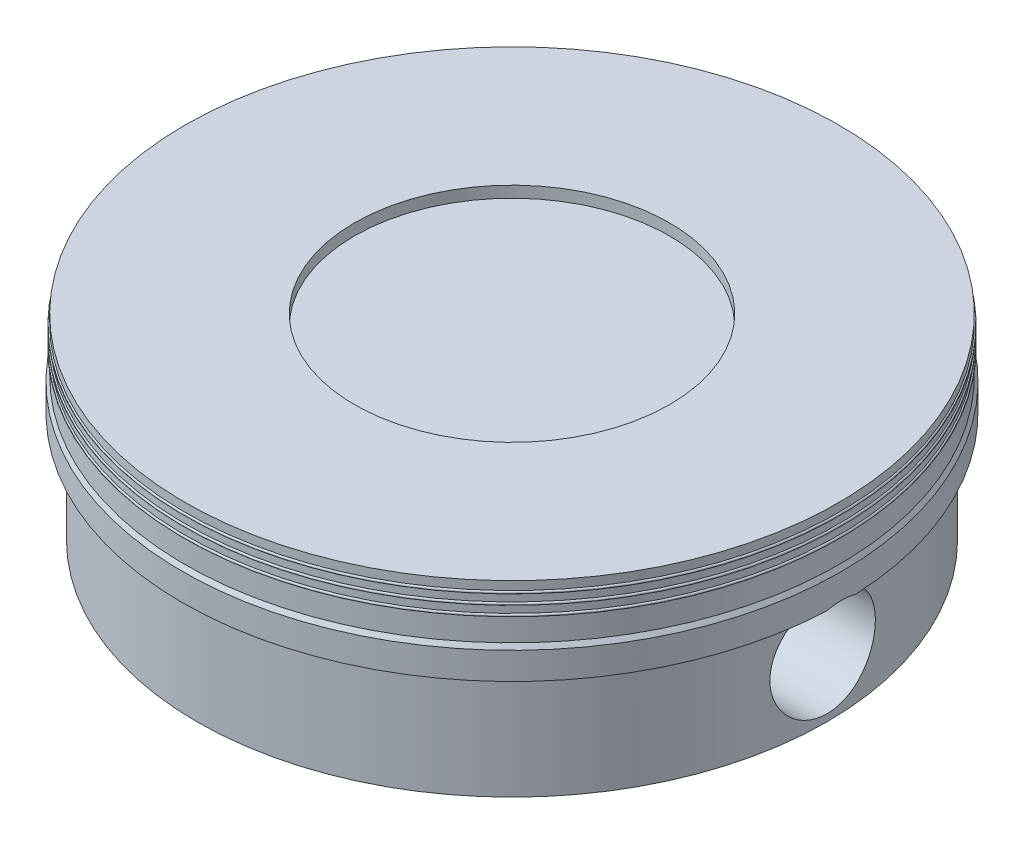
from build123d import *

# Parameters (mm, degrees)
BOSS_EXTRUDE2_DEPTH     = 2.032
SKETCH5_R               = 0.8
CUT_EXTRUDE1_DEPTH      = 6
CUT_EXTRUDE1_DEPTH_BACK = 6


with BuildPart() as part:
    # Sketch1 → Revolve1 (revolve)
    with BuildSketch(Plane.XY):
        with BuildLine():
            Line((4.78, 0), (3.43, 0))
            Line((3.43, 0), (3.43, 1.93))
            Line((3.43, 1.93), (4.2, 1.93))
            Line((4.2, 1.93), (4.2, 2.33))
            Line((4.2, 2.33), (0, 2.33))
            Line((0, 2.33), (0, 2.8))
            Line((0, 2.8), (2.39, 2.8))
            Line((2.39, 2.8), (2.39, 2.972))
            Line((2.39, 2.972), (4.96, 2.972))
            Line((4.96, 2.972), (4.96, 2.842))
            ThreePointArc((4.96, 2.842), (4.98, 2.822), (4.96, 2.802))
            Line((4.96, 2.802), (4.96, 2.692))
            ThreePointArc((4.96, 2.692), (4.98, 2.672), (4.96, 2.652))
            Line((4.96, 2.652), (4.96, 2.542))
            ThreePointArc((4.96, 2.542), (4.98, 2.522), (4.96, 2.502))
            Line((4.96, 2.502), (4.96, 2.155))
            Line((4.96, 2.155), (5, 2.085))
            Line((5, 2.085), (5, 1.675))
            Line((5, 1.675), (4.78, 1.675))
            Line((4.78, 1.675), (4.78, 0))
        make_face()
    revolve(axis=Axis((0, 3, 0), (0, -1, 0)))

    # Sketch4 → Boss-Extrude2 (add)
    with BuildSketch(Plane.XZ):
        with BuildLine():
            Line((-1.75, 2.949983051), (-1.75, -2.949983051))
            ThreePointArc((-1.75, -2.949983051), (-3.43, 0), (-1.75, 2.949983051))
        make_face()
        with BuildLine():
            Line((1.75, 2.949983051), (1.75, -2.949983051))
            ThreePointArc((1.75, -2.949983051), (3.43, 0), (1.75, 2.949983051))
        make_face()
    extrude(amount=-BOSS_EXTRUDE2_DEPTH)

    # Sketch5 → Cut-Extrude1 (cut, two sides)
    with BuildSketch(Plane(origin=(0, 0, 0), x_dir=(0, 0, -1), z_dir=(1, 0, 0))) as cut_extrude1_sk:
        with Locations((0, 0.9065)):
            Circle(SKETCH5_R)
    extrude(amount=CUT_EXTRUDE1_DEPTH, mode=Mode.SUBTRACT)
    extrude(cut_extrude1_sk.sketch, amount=-CUT_EXTRUDE1_DEPTH_BACK, mode=Mode.SUBTRACT)


solid = part.part
